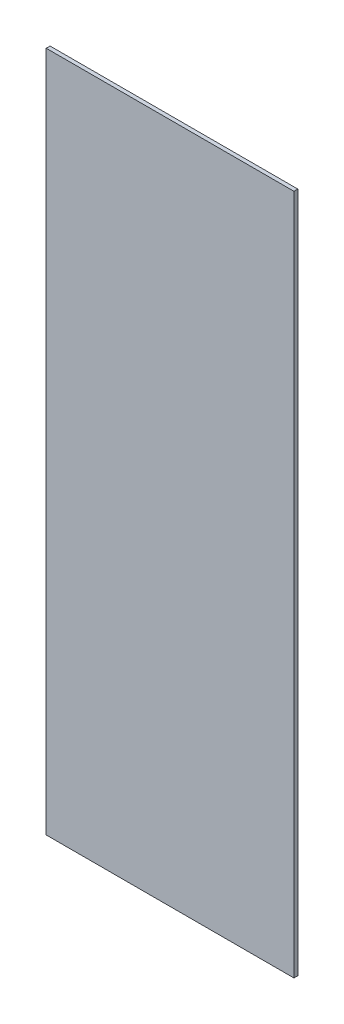
from build123d import *

# Parameters (mm, degrees)
SKETCH1_W           = 50.8
SKETCH1_H           = 139.7
BOSS_EXTRUDE1_DEPTH = 0.79375


with BuildPart() as part:
    # Sketch1 → Boss-Extrude1 (new body)
    with BuildSketch(Plane.XY):
        with Locations((25.4, 69.85)):
            Rectangle(SKETCH1_W, SKETCH1_H)
    extrude(amount=BOSS_EXTRUDE1_DEPTH)


solid = part.part
